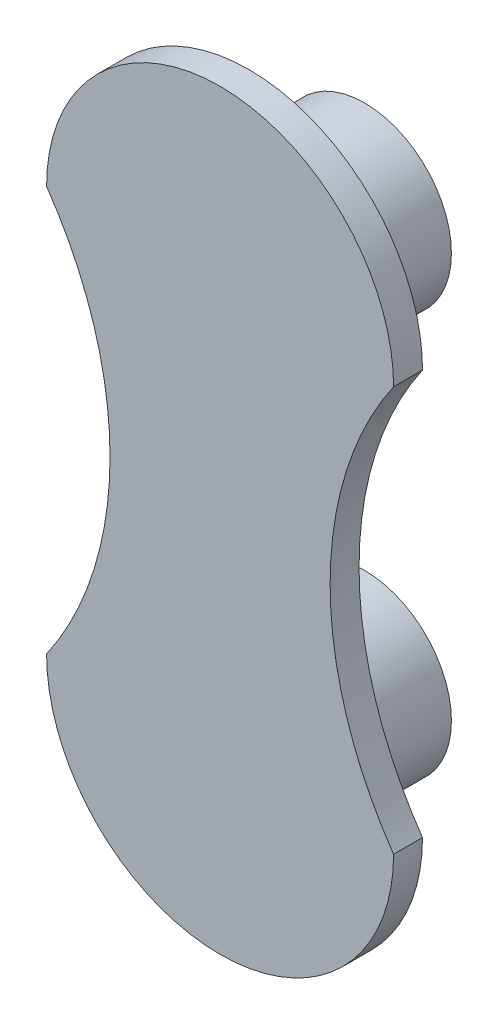
from build123d import *

# Parameters (mm, degrees)
BOSS_EXTRUDE1_DEPTH = 6.35
SKETCH2_R           = 19.05
BOSS_EXTRUDE2_DEPTH = 25.4


with BuildPart() as part:
    # Sketch1 → Boss-Extrude1 (new body)
    with BuildSketch(Plane.XY):
        with BuildLine():
            ThreePointArc((38.1, 59.170454545), (0, 97.270454545), (-38.1, 59.170454545))
            ThreePointArc((-38.1, 59.170454545), (-24.166339939, 14.720454545), (-38.1, -29.729545455))
            ThreePointArc((-38.1, -29.729545455), (0, -67.829545455), (38.1, -29.729545455))
            ThreePointArc((38.1, -29.729545455), (24.166339939, 14.720454545), (38.1, 59.170454545))
        make_face()
    extrude(amount=BOSS_EXTRUDE1_DEPTH)

    # Sketch2 → Boss-Extrude2 (add)
    with BuildSketch(Plane(origin=(0, 0, 0), x_dir=(-1, 0, 0), z_dir=(0, 0, -1))):
        with Locations((0, 59.170454545)):
            Circle(SKETCH2_R)
        with Locations((0, -29.729545455)):
            Circle(SKETCH2_R)
    extrude(amount=BOSS_EXTRUDE2_DEPTH)


solid = part.part
